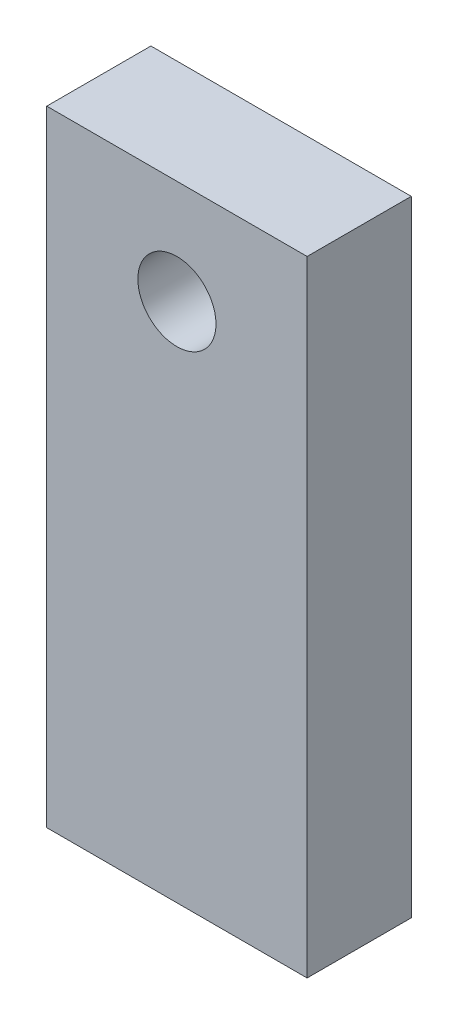
from build123d import *

# Parameters (mm, degrees)
SKIZZE4_R                            = 3
AUFSATZ_LINEAR_AUSTRAGEN1_DEPTH      = 4
AUFSATZ_LINEAR_AUSTRAGEN1_DEPTH_BACK = 4


with BuildPart() as part:
    # Skizze4 → Aufsatz-Linear austragen1 (new body, two sides)
    with BuildSketch(Plane.XY) as aufsatz_linear_austragen1_sk:
        Polygon((-10, 610), (-10, 570), (10, 570), (10, 610), (10, 618), (-10, 618), align=None)
        with Locations((0, 610)):
            Circle(SKIZZE4_R, mode=Mode.SUBTRACT)
    extrude(amount=AUFSATZ_LINEAR_AUSTRAGEN1_DEPTH)
    extrude(aufsatz_linear_austragen1_sk.sketch, amount=-AUFSATZ_LINEAR_AUSTRAGEN1_DEPTH_BACK)


solid = part.part
